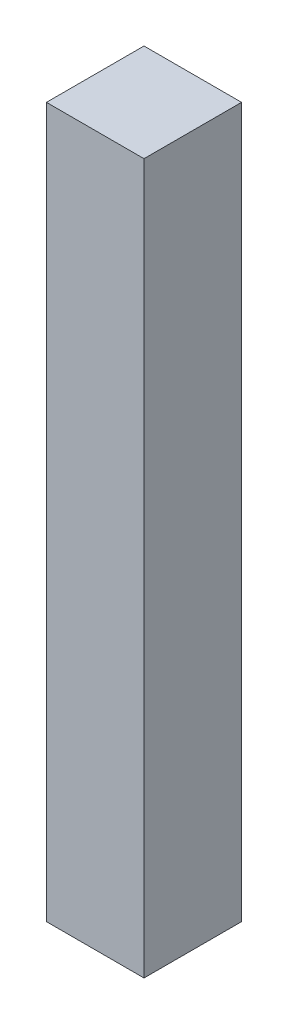
from build123d import *

# Parameters (mm, degrees)
SKETCH1_W           = 2.75
SKETCH1_H           = 2.75
BOSS_EXTRUDE1_DEPTH = 20


with BuildPart() as part:
    # Sketch1 → Boss-Extrude1 (new body)
    with BuildSketch(Plane(origin=(0, 0, 0), x_dir=(1, 0, 0), z_dir=(0, 1, 0))):
        with Locations((1.375, 1.375)):
            Rectangle(SKETCH1_W, SKETCH1_H)
    extrude(amount=BOSS_EXTRUDE1_DEPTH)


solid = part.part
